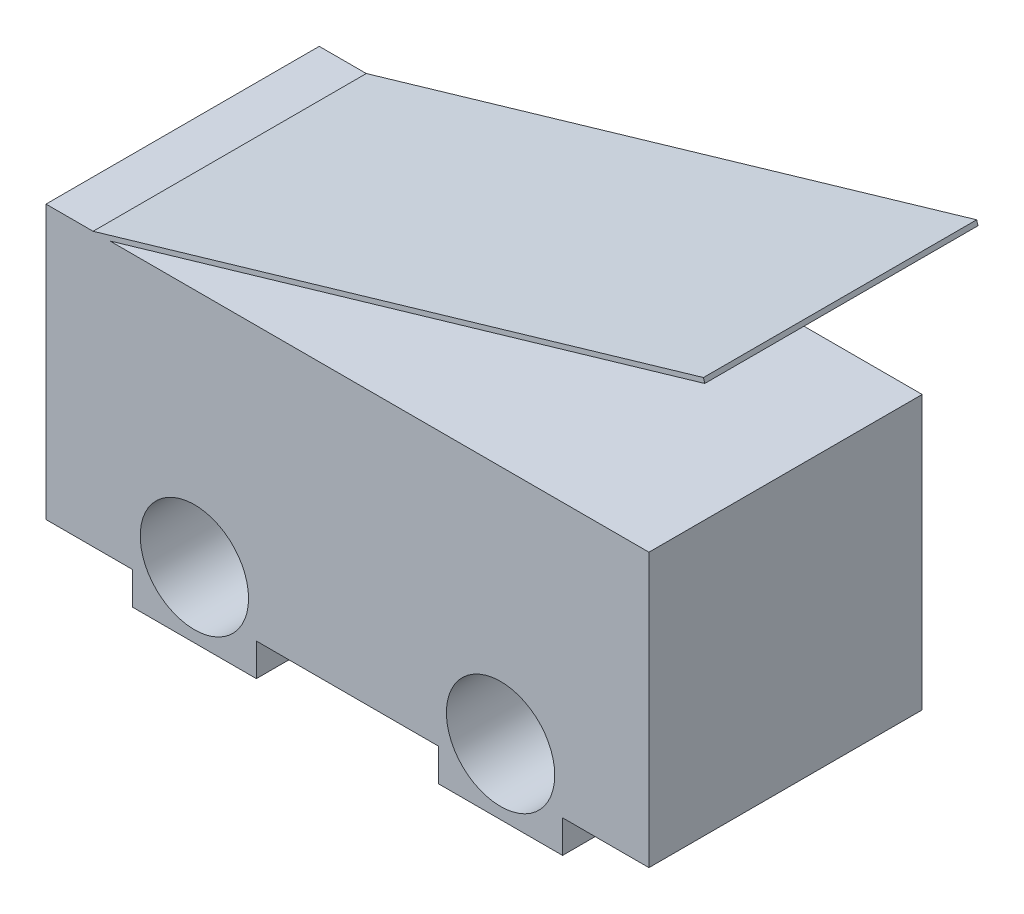
from build123d import *

# Parameters (mm, degrees)
SKETCH1_R           = 1.15
BOSS_EXTRUDE1_DEPTH = 5.8
EXTRUDE_THIN1_DEPTH = 5.8


with BuildPart() as part:
    # Sketch1 → Boss-Extrude1 (new body)
    with BuildSketch(Plane.XY):
        Polygon((-6.4, -2.9), (-4.565838245, -2.9), (-4.565838245, -3.592341201), (-1.934161755, -3.592341201), (-1.934161755, -2.9), (1.934161755, -2.9), (1.934161755, -3.592341201), (4.565838245, -3.592341201), (4.565838245, -2.9), (6.4, -2.9), (6.4, 2.9), (-6.4, 2.9), align=None)
        with Locations((-3.25, -2.2)):
            Circle(SKETCH1_R, mode=Mode.SUBTRACT)
        with Locations((3.25, -2.2)):
            Circle(SKETCH1_R, mode=Mode.SUBTRACT)
    extrude(amount=-BOSS_EXTRUDE1_DEPTH)

    # Sketch2 → Extrude-Thin1 (add)
    with BuildSketch(Plane.XY):
        Polygon((-5.4, 2.9), (7.557079146, 6.69), (7.58515322, 6.594021636), (-5.371925926, 2.804021636), align=None)
    extrude(amount=-EXTRUDE_THIN1_DEPTH)


solid = part.part
